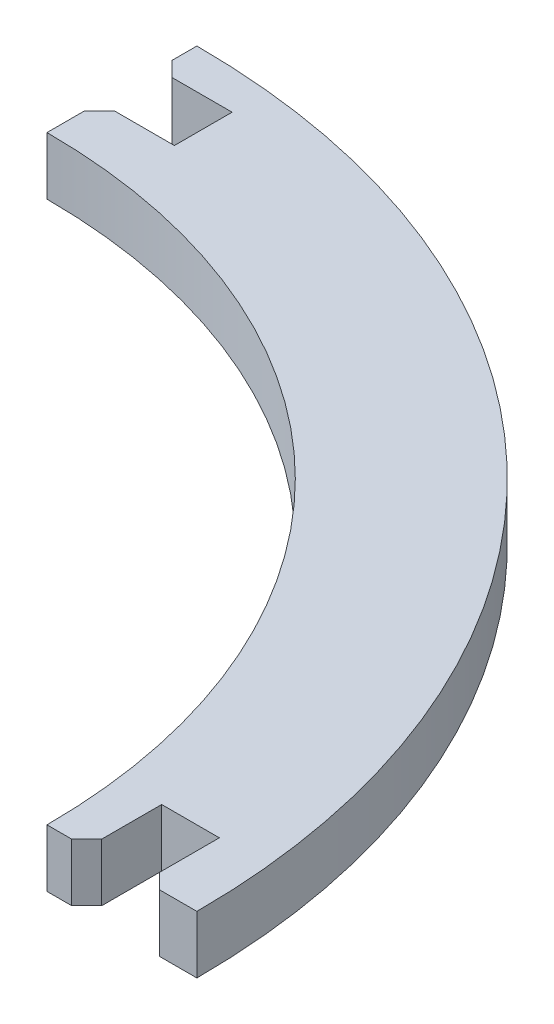
from build123d import *

# Parameters (mm, degrees)
BOSS_EXTRUDE1_DEPTH = 3.85
CHAMFER1_SIZE       = 1


with BuildPart() as part:
    # Sketch1 → Boss-Extrude1 (new body)
    with BuildSketch(Plane(origin=(0, 0, 0), x_dir=(1, 0, 0), z_dir=(0, 1, 0))):
        with BuildLine():
            Line((0, 50), (0, 47.35))
            Line((0, 47.35), (5, 47.35))
            Line((5, 47.35), (5, 43.5))
            Line((5, 43.5), (0, 43.5))
            Line((0, 43.5), (0, 40))
            ThreePointArc((0, 40), (28.284271247, 28.284271247), (40, 0))
            Line((40, 0), (42.65, 0))
            Line((42.65, 0), (42.65, 5))
            Line((42.65, 5), (46.5, 5))
            Line((46.5, 5), (46.5, 0))
            Line((46.5, 0), (50, 0))
            ThreePointArc((50, 0), (35.355339059, 35.355339059), (0, 50))
        make_face()
    extrude(amount=BOSS_EXTRUDE1_DEPTH)

    # Chamfer1
    chamfer1_edges = [part.edges().sort_by_distance(p)[0] for p in [
        (0, 1.925, -43.5),
        (0, 1.925, -47.35),
        (46.5, 1.925, 0),
        (42.65, 1.925, 0),
    ]]
    chamfer(chamfer1_edges, length=CHAMFER1_SIZE)


solid = part.part
